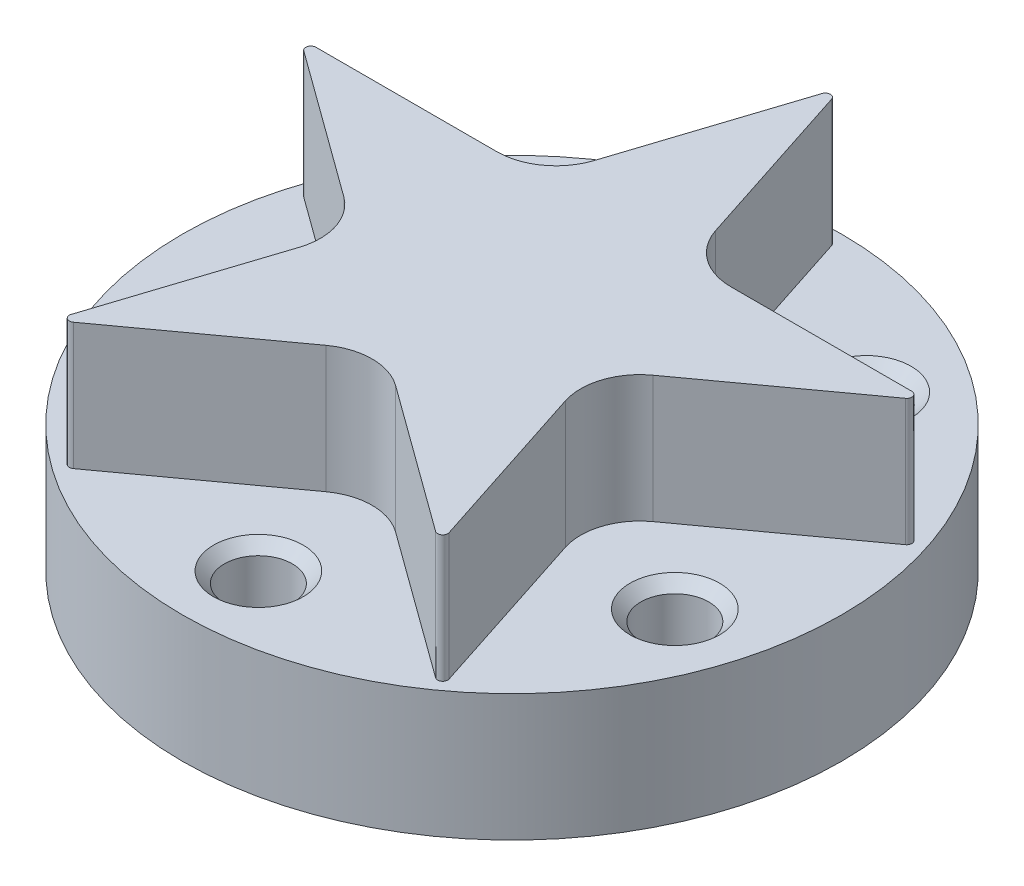
from build123d import *

# Parameters (mm, degrees)
SKETCH1_R                         = 24.765
BOSS_EXTRUDE1_DEPTH               = 19.05
SKETCH2_OUTSIDE_W                 = 66.048
SKETCH2_OUTSIDE_H                 = 66.048
CUT_EXTRUDE1_DEPTH                = 9.525
F_1_4_20_TAPPED_HOLE5_D           = 5.1054
F_1_4_20_TAPPED_HOLE5_DEPTH       = 7.62
F_1_4_20_TAPPED_HOLE5_CSINK_D     = 6.731
F_1_4_20_TAPPED_HOLE5_CSINK_ANGLE = 90
F_1_4_20_TAPPED_HOLE5_TIP         = 1.533816902


with BuildPart() as part:
    # Sketch1 → Boss-Extrude1 (new body)
    with BuildSketch(Plane(origin=(0, 0, 0), x_dir=(1, 0, 0), z_dir=(0, 1, 0))):
        Circle(SKETCH1_R)
    extrude(amount=BOSS_EXTRUDE1_DEPTH)

    # Sketch2 outside → Cut-Extrude1 (cut)
    with BuildSketch(Plane(origin=(0, 19.05, 0), x_dir=(1, 0, 0), z_dir=(0, 1, 0))):
        Rectangle(SKETCH2_OUTSIDE_W, SKETCH2_OUTSIDE_H)
        with BuildLine():
            Line((-14.19414924, -18.920099441), (-9.994377531, -5.994531191))
            ThreePointArc((-9.994377531, -5.994531191), (-9.994377531, -3.247370111), (-11.609118299, -1.024870111))
            Line((-11.609118299, -1.024870111), (-22.60426338, 6.963570391))
            ThreePointArc((-22.60426338, 6.963570391), (-22.742669731, 7.389541341), (-22.380317198, 7.652805866))
            Line((-22.380317198, 7.652805866), (-8.789570457, 7.652805866))
            ThreePointArc((-8.789570457, 7.652805866), (-6.176865011, 8.501725326), (-4.562124242, 10.724225326))
            Line((-4.562124242, 10.724225326), (-0.362352533, 23.649793575))
            ThreePointArc((-0.362352533, 23.649793575), (0, 23.913058101), (0.362352533, 23.649793575))
            Line((0.362352533, 23.649793575), (4.562124242, 10.724225326))
            ThreePointArc((4.562124242, 10.724225326), (6.176865011, 8.501725326), (8.789570457, 7.652805866))
            Line((8.789570457, 7.652805866), (22.380317198, 7.652805866))
            ThreePointArc((22.380317198, 7.652805866), (22.742669731, 7.389541341), (22.60426338, 6.963570391))
            Line((22.60426338, 6.963570391), (11.609118299, -1.024870111))
            ThreePointArc((11.609118299, -1.024870111), (9.994377531, -3.247370111), (9.994377531, -5.994531191))
            Line((9.994377531, -5.994531191), (14.19414924, -18.920099441))
            ThreePointArc((14.19414924, -18.920099441), (14.055742889, -19.346070391), (13.607850526, -19.346070391))
            Line((13.607850526, -19.346070391), (2.612705446, -11.357629889))
            ThreePointArc((2.612705446, -11.357629889), (0, -10.508710429), (-2.612705446, -11.357629889))
            Line((-2.612705446, -11.357629889), (-13.607850526, -19.346070391))
            ThreePointArc((-13.607850526, -19.346070391), (-14.055742889, -19.346070391), (-14.19414924, -18.920099441))
        make_face(mode=Mode.SUBTRACT)
    extrude(amount=-CUT_EXTRUDE1_DEPTH, mode=Mode.SUBTRACT)

    # 1/4-20 Tapped Hole5
    with Locations(Plane(origin=(0, 9.525, 0), x_dir=(1, 0, 0), z_dir=(0, 1, 0))):
        with Locations((-18.117626635, -5.886773743), (-11.197309056, 15.411773743), (11.197309056, 15.411773743), (18.117626635, -5.886773743), (0, -19.05)):
            CounterSinkHole(F_1_4_20_TAPPED_HOLE5_D / 2, F_1_4_20_TAPPED_HOLE5_CSINK_D / 2, depth=F_1_4_20_TAPPED_HOLE5_DEPTH, counter_sink_angle=F_1_4_20_TAPPED_HOLE5_CSINK_ANGLE)
            with Locations((0, 0, -(F_1_4_20_TAPPED_HOLE5_DEPTH + F_1_4_20_TAPPED_HOLE5_TIP / 2))):  # 118° drill point
                Cone(0, F_1_4_20_TAPPED_HOLE5_D / 2, F_1_4_20_TAPPED_HOLE5_TIP, mode=Mode.SUBTRACT)


solid = part.part
